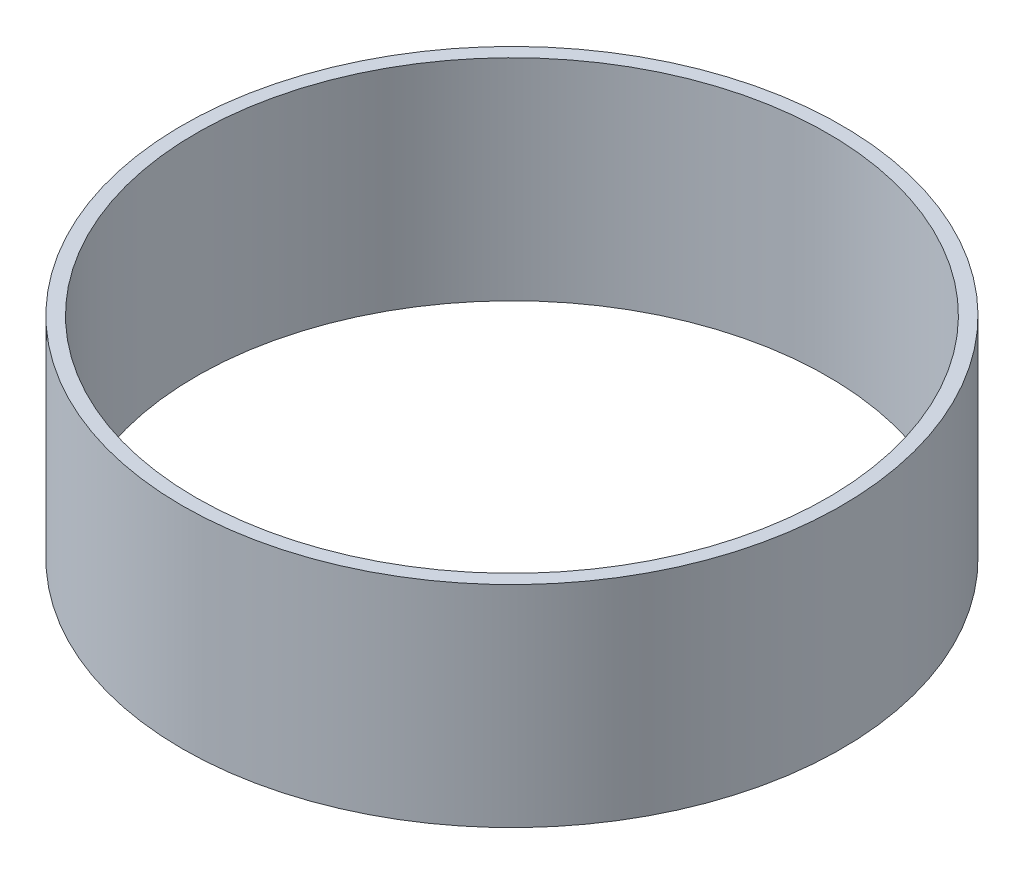
from build123d import *

# Parameters (mm, degrees)
SKETCH1_R           = 75.565
SKETCH1_R_2         = 72.39
BOSS_EXTRUDE1_DEPTH = 48.26


with BuildPart() as part:
    # Sketch1 → Boss-Extrude1 (new body)
    with BuildSketch(Plane(origin=(0, 0, 0), x_dir=(1, 0, 0), z_dir=(0, 1, 0))):
        Circle(SKETCH1_R)
        Circle(SKETCH1_R_2, mode=Mode.SUBTRACT)
    extrude(amount=BOSS_EXTRUDE1_DEPTH)


solid = part.part
